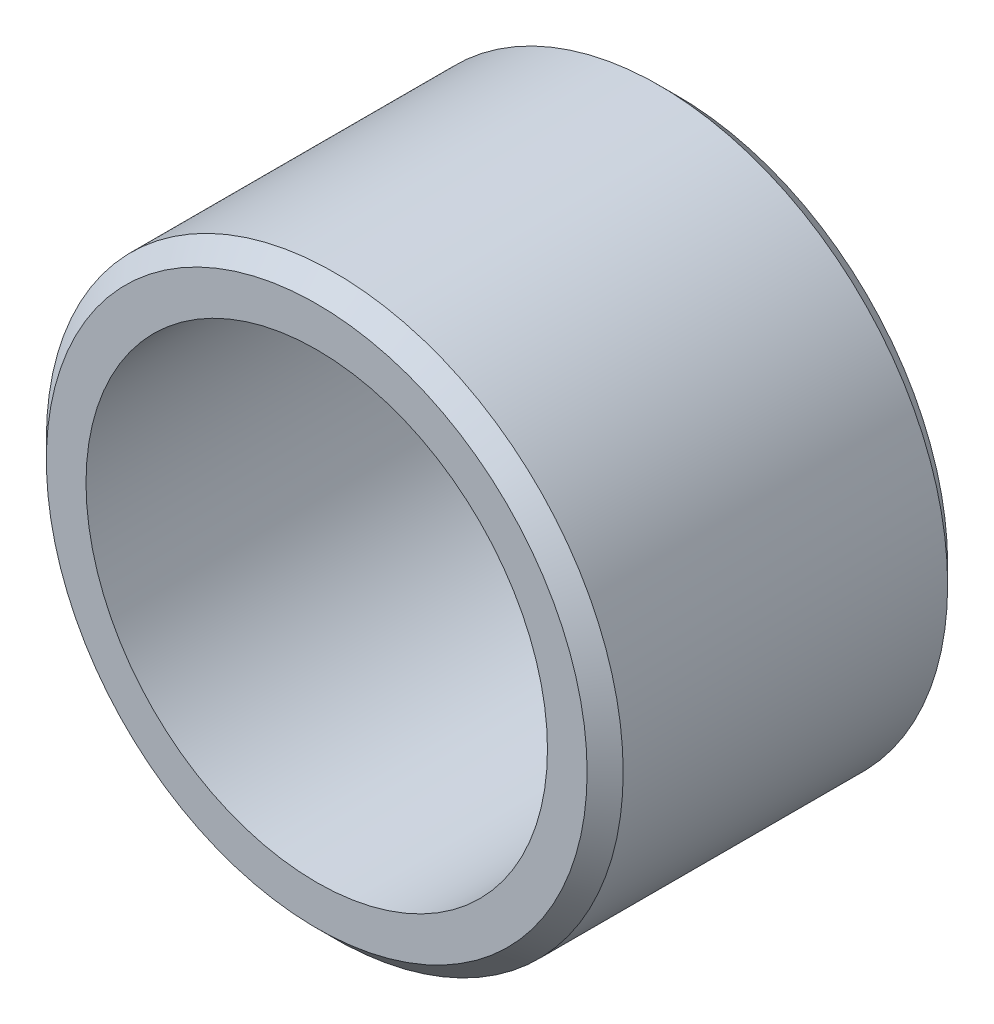
from build123d import *

# Parameters (mm, degrees)
SKETCH1_R           = 4
SKETCH1_R_2         = 3.2
BOSS_EXTRUDE1_DEPTH = 5
CHAMFER1_SIZE       = 0.25


with BuildPart() as part:
    # Sketch1 → Boss-Extrude1 (new body)
    with BuildSketch(Plane.XY):
        Circle(SKETCH1_R)
        Circle(SKETCH1_R_2, mode=Mode.SUBTRACT)
    extrude(amount=BOSS_EXTRUDE1_DEPTH)

    # Chamfer1
    chamfer1_edges = [part.edges().sort_by_distance(p)[0] for p in [
        (-4, 0, 0),
        (-4, 0, 5),
    ]]
    chamfer(chamfer1_edges, length=CHAMFER1_SIZE)


solid = part.part
